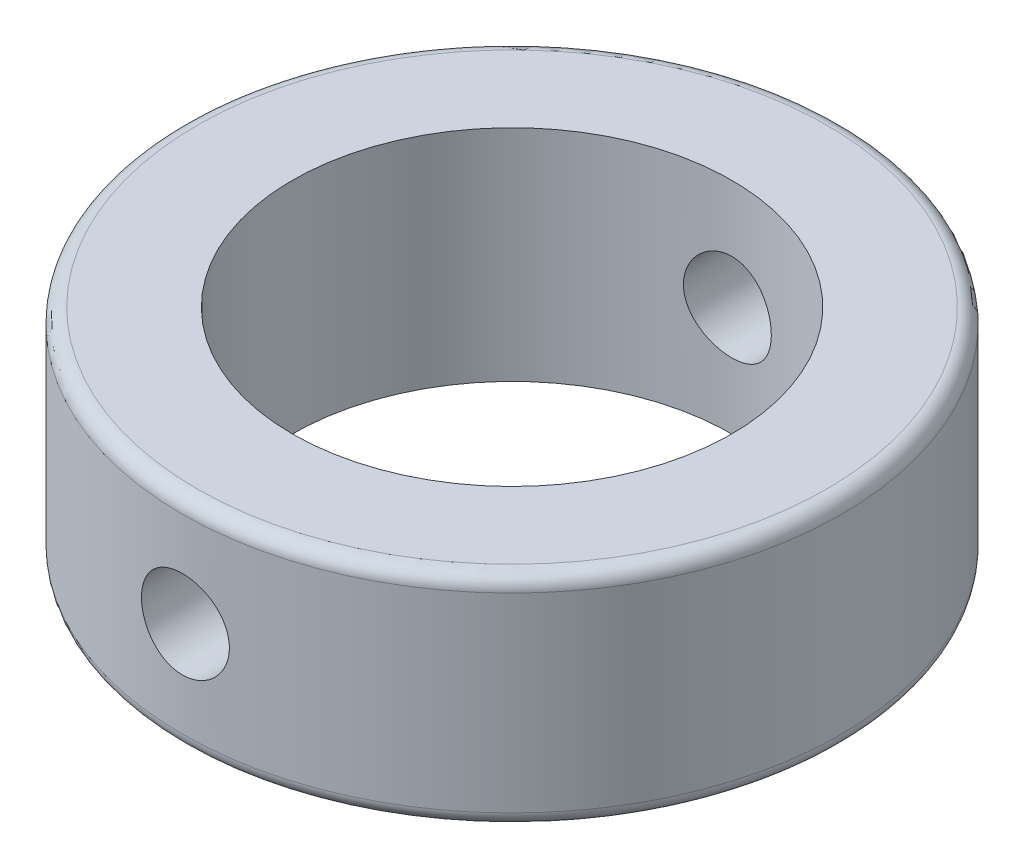
from build123d import *

# Parameters (mm, degrees)
SKETCH1_R               = 22.5
SKETCH1_R_2             = 15
BOSS_EXTRUDE1_DEPTH     = 15
SKETCH2_R               = 3
CUT_EXTRUDE1_DEPTH      = 23.5
CUT_EXTRUDE1_DEPTH_BACK = 23.5
FILLET1_R               = 1


with BuildPart() as part:
    # Sketch1 → Boss-Extrude1 (new body)
    with BuildSketch(Plane(origin=(0, 0, 0), x_dir=(1, 0, 0), z_dir=(0, 1, 0))):
        Circle(SKETCH1_R)
        Circle(SKETCH1_R_2, mode=Mode.SUBTRACT)
    extrude(amount=BOSS_EXTRUDE1_DEPTH)

    # Sketch2 → Cut-Extrude1 (cut, two sides)
    with BuildSketch(Plane.XY) as cut_extrude1_sk:
        with Locations((0, 7.5)):
            Circle(SKETCH2_R)
    extrude(amount=CUT_EXTRUDE1_DEPTH, mode=Mode.SUBTRACT)
    extrude(cut_extrude1_sk.sketch, amount=-CUT_EXTRUDE1_DEPTH_BACK, mode=Mode.SUBTRACT)

    # Fillet1
    fillet1_edges = [part.edges().sort_by_distance(p)[0] for p in [
        (-22.5, 0, 0),
        (-22.5, 15, 0),
    ]]
    fillet(fillet1_edges, radius=FILLET1_R)


solid = part.part
